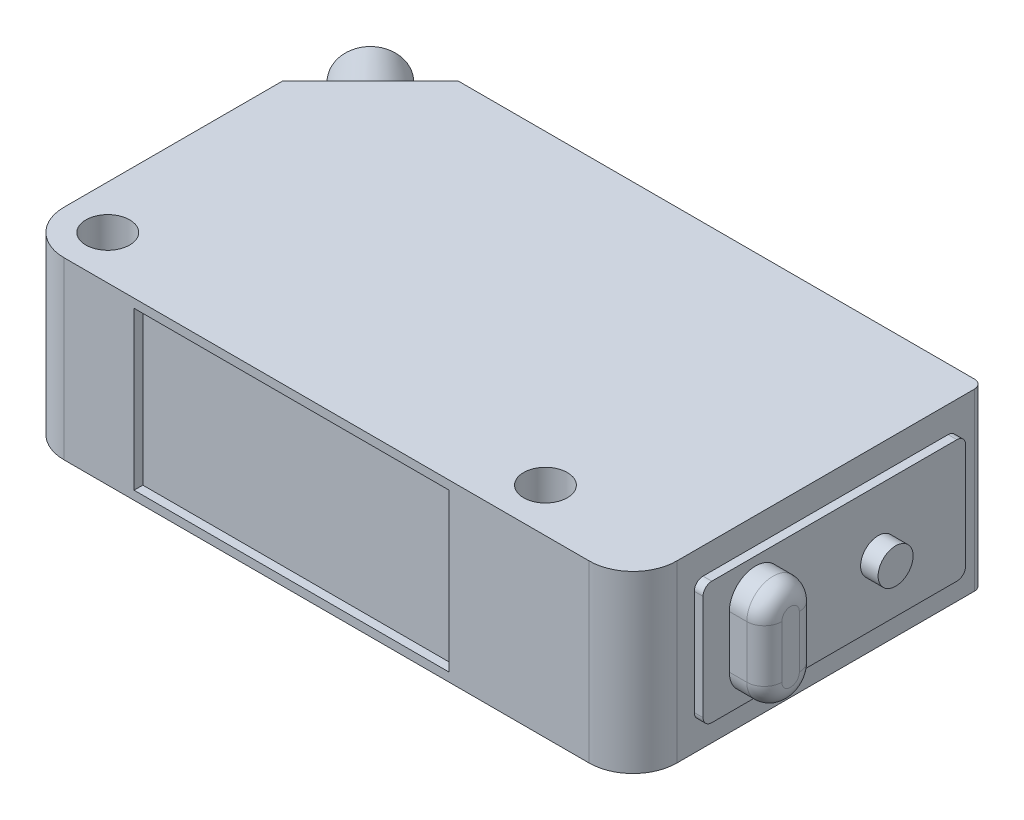
from build123d import *

# Parameters (mm, degrees)
SKETCH_1_R             = 0.5
EXTRUDE_1_DEPTH        = 10
HOLE_WIZARD_M3_1_D     = 2.5
HOLE_WIZARD_M3_1_DEPTH = 18.5
HOLE_WIZARD_M3_1_TIP   = 0.751075774
SKETCH_4_R             = 0.5
EXTRUDE_2_DEPTH        = 10
HOLE_WIZARD_M3_2_D     = 2.5
HOLE_WIZARD_M3_2_DEPTH = 18.5
HOLE_WIZARD_M3_2_TIP   = 0.751075774
SKETCH_6_W             = 18
SKETCH_6_H             = 9
CUT_EXTRUDE_1_DEPTH    = 0.5
EXTRUDE_3_DEPTH        = 0.5
EXTRUDE_4_DEPTH        = 2
FILLET_4_R             = 1
SKETCH_10_R            = 1
EXTRUDE_5_DEPTH        = 1
SKETCH_11_W            = 12
SKETCH_11_H            = 7
EXTRUDE_6_DEPTH        = 0.1
SKETCH_12_R            = 1
EXTRUDE_7_DEPTH        = 1
SKETCH_13_R            = 1.75
EXTRUDE_8_DEPTH        = 7
DRAFT_1_ANGLE          = 5


with BuildPart() as part:
    # 草图1 → 凸台-拉伸1 (new body)
    with BuildSketch(Plane(origin=(0, 0, 0), x_dir=(1, 0, 0), z_dir=(0, 1, 0))):
        with BuildLine():
            Line((-12.5, 10), (-17.5, 5))
            Line((-17.5, 5), (-17.5, -7.5))
            ThreePointArc((-17.5, -7.5), (-16.767766953, -9.267766953), (-15, -10))
            Line((-15, -10), (15, -10))
            ThreePointArc((15, -10), (16.767766953, -9.267766953), (17.5, -7.5))
            Line((17.5, -7.5), (17.5, 9.5))
            ThreePointArc((17.5, 9.5), (17.353553391, 9.853553391), (17, 10))
            Line((17, 10), (-12.5, 10))
        make_face()
        with Locations((-15, -7.5)):
            Circle(SKETCH_1_R, mode=Mode.SUBTRACT)
    extrude(amount=EXTRUDE_1_DEPTH)

    # M3 螺纹孔1
    with Locations(Plane(origin=(10, 10, 7.5), x_dir=(0, 0, 1), z_dir=(0, 1, 0))):
        with Locations((0, 0)):
            Hole(HOLE_WIZARD_M3_1_D / 2, depth=HOLE_WIZARD_M3_1_DEPTH)
            with Locations((0, 0, -(HOLE_WIZARD_M3_1_DEPTH + HOLE_WIZARD_M3_1_TIP / 2))):  # 118° drill point
                Cone(0, HOLE_WIZARD_M3_1_D / 2, HOLE_WIZARD_M3_1_TIP, mode=Mode.SUBTRACT)

    # 草图4 → 凸台-拉伸2 (add)
    with BuildSketch(Plane.XZ):
        with Locations((-15, 7.5)):
            Circle(SKETCH_4_R)
    extrude(amount=-EXTRUDE_2_DEPTH)

    # M3 螺纹孔2
    with Locations(Plane(origin=(-15, 10, 7.5), x_dir=(0, 0, 1), z_dir=(0, 1, 0))):
        with Locations((0, 0)):
            Hole(HOLE_WIZARD_M3_2_D / 2, depth=HOLE_WIZARD_M3_2_DEPTH)
            with Locations((0, 0, -(HOLE_WIZARD_M3_2_DEPTH + HOLE_WIZARD_M3_2_TIP / 2))):  # 118° drill point
                Cone(0, HOLE_WIZARD_M3_2_D / 2, HOLE_WIZARD_M3_2_TIP, mode=Mode.SUBTRACT)

    # 草图6 → 切除-拉伸1 (cut)
    with BuildSketch(Plane.XY.offset(10)):
        with Locations((-2, 5)):
            Rectangle(SKETCH_6_W, SKETCH_6_H)
    extrude(amount=-CUT_EXTRUDE_1_DEPTH, mode=Mode.SUBTRACT)

    # 草图8 → 凸台-拉伸3 (add)
    with BuildSketch(Plane(origin=(17.5, 0, 0), x_dir=(0, 0, -1), z_dir=(1, 0, 0))):
        with BuildLine():
            Line((8, 8.5), (-6, 8.5))
            ThreePointArc((-6, 8.5), (-6.353553391, 8.353553391), (-6.5, 8))
            Line((-6.5, 8), (-6.5, 2))
            ThreePointArc((-6.5, 2), (-6.353553391, 1.646446609), (-6, 1.5))
            Line((-6, 1.5), (8, 1.5))
            ThreePointArc((8, 1.5), (8.353553391, 1.646446609), (8.5, 2))
            Line((8.5, 2), (8.5, 8))
            ThreePointArc((8.5, 8), (8.353553391, 8.353553391), (8, 8.5))
        make_face()
    extrude(amount=EXTRUDE_3_DEPTH)

    # 草图9 → 凸台-拉伸4 (add)
    with BuildSketch(Plane(origin=(18, 0, 0), x_dir=(0, 0, -1), z_dir=(1, 0, 0))):
        with BuildLine():
            Line((-2, 6.5), (-2, 3.5))
            ThreePointArc((-2, 3.5), (-3.5, 2), (-5, 3.5))
            Line((-5, 3.5), (-5, 6.5))
            ThreePointArc((-5, 6.5), (-3.5, 8), (-2, 6.5))
        make_face()
    extrude(amount=EXTRUDE_4_DEPTH)

    # 圆角4
    fillet_4_edges = [part.edges().sort_by_distance(p)[0] for p in [
        (20, 8, 3.5),
        (20, 5, 5),
        (20, 2, 3.5),
        (20, 5, 2),
    ]]
    fillet(fillet_4_edges, radius=FILLET_4_R)

    # 草图10 → 凸台-拉伸5 (add)
    with BuildSketch(Plane(origin=(18, 0, 0), x_dir=(0, 0, -1), z_dir=(1, 0, 0))):
        with Locations((3.5, 5)):
            Circle(SKETCH_10_R)
    extrude(amount=EXTRUDE_5_DEPTH)

    # 草图11 → 凸台-拉伸6 (add)
    with BuildSketch(Plane(origin=(0, 0, -10), x_dir=(-1, 0, 0), z_dir=(0, 0, -1))):
        with Locations((-2.25, 5)):
            Rectangle(SKETCH_11_W, SKETCH_11_H)
    extrude(amount=EXTRUDE_6_DEPTH)

    # 草图12 → 凸台-拉伸7 (add)
    with BuildSketch(Plane(origin=(0, 0, -10), x_dir=(-1, 0, 0), z_dir=(0, 0, -1))):
        with Locations((-11.25, 5)):
            Circle(SKETCH_12_R)
        with Locations((6.75, 5)):
            Circle(SKETCH_12_R)
    extrude(amount=EXTRUDE_7_DEPTH)

    # 草图13 → 凸台-拉伸8 (add)
    with BuildSketch(Plane(origin=(-11.25, 0, -11.25), x_dir=(-0.707106781, 0, 0.707106781), z_dir=(-0.707106781, 0, -0.707106781))):
        with Locations((5.303300859, 5)):
            Circle(SKETCH_13_R)
    extrude(amount=EXTRUDE_8_DEPTH)

    # 拔模1
    draft_1_faces = [part.faces().sort_by_distance(p)[0] for p in [
        (-16.237436867, 5, -11.212310601),
    ]]
    draft(draft_1_faces, Plane(origin=(-19.949747468, 5, -12.449747468), x_dir=(-0.707106781, 0, 0.707106781), z_dir=(-0.707106781, 0, -0.707106781)), DRAFT_1_ANGLE)


solid = part.part
